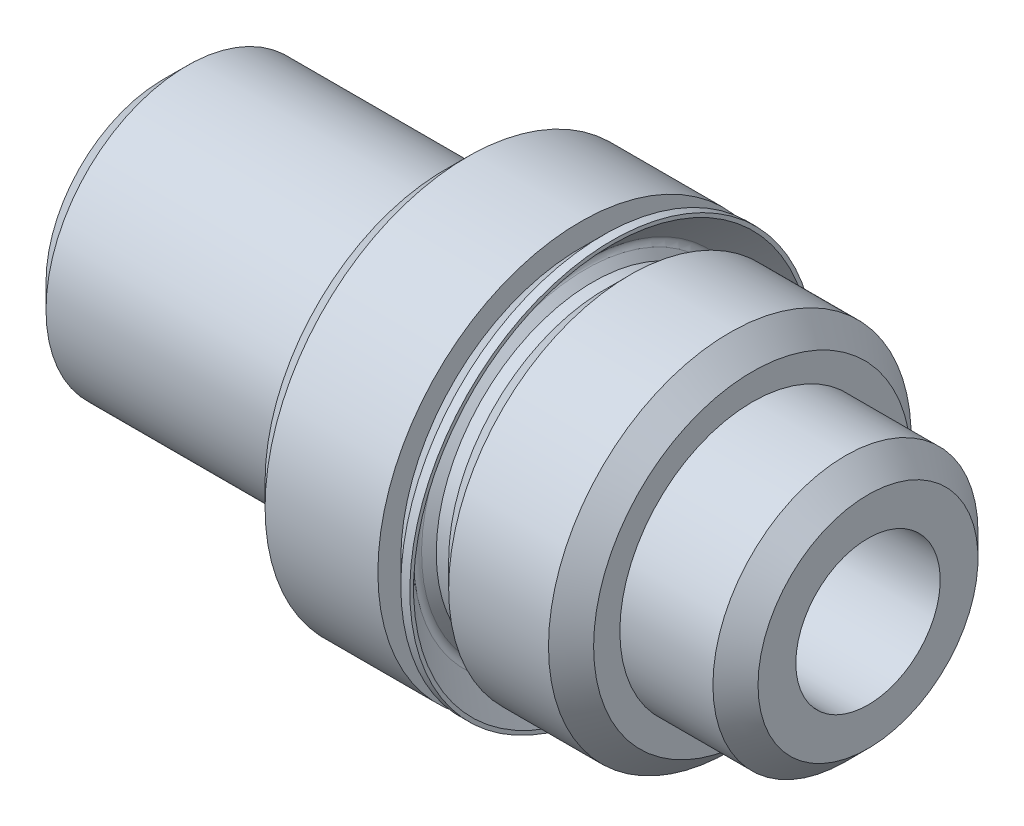
from build123d import *

# Parameters (mm, degrees)
HOLE1_D           = 3.2512
HOLE1_CSINK_D     = 4.0132
HOLE1_CSINK_ANGLE = 90


with BuildPart() as part:
    # Sketch1 → Revolve1 (revolve)
    with BuildSketch(Plane.XY):
        Polygon((0, 0), (0, 2.63398), (0.54102, 3.175), (6.35, 3.175), (6.35, 0), align=None)
    revolve(axis=Axis((6.35, 0, 0), (-1, 0, 0)))

    # Sketch2 → Revolve2 (revolve)
    with BuildSketch(Plane.XY):
        Polygon((6.35, 0), (6.35, 4.0513), (6.858, 4.5593), (9.398, 4.5593), (9.398, 3.52425), (9.9568, 3.52425), (10.5156, 4.08305), (12.7635, 4.08305), (13.2715, 3.57505), (13.2715, 0), align=None)
    revolve(axis=Axis((13.2715, 0, 0), (-1, 0, 0)))

    # Sketch3 → Revolve3 (revolve)
    with BuildSketch(Plane.XY):
        Polygon((13.2715, 0), (13.2715, 2.9845), (15.367, 2.9845), (15.875, 2.4765), (15.875, 0), align=None)
    revolve(axis=Axis((15.875, 0, 0), (-1, 0, 0)))

    # Hole1 (through all)
    with Locations(Plane.ZY):
        with Locations((0, 0)):
            CounterSinkHole(HOLE1_D / 2, HOLE1_CSINK_D / 2, counter_sink_angle=HOLE1_CSINK_ANGLE)

    # Sketch6 → Revolve4 (revolve)
    with BuildSketch(Plane.XY):
        with BuildLine():
            Line((9.398, 3.27025), (9.9568, 3.27025))
            Line((9.9568, 3.27025), (9.9568, 3.52425))
            Line((9.9568, 3.52425), (9.6774, 3.52425))
            Line((9.6774, 3.52425), (9.511771292, 3.689878708))
            ThreePointArc((9.511771292, 3.689878708), (9.474573853, 3.779681269), (9.511771292, 3.869483831))
            Line((9.511771292, 3.869483831), (10.117419265, 4.475131804))
            Line((10.117419265, 4.475131804), (10.117419265, 4.5593))
            Line((10.117419265, 4.5593), (9.914219265, 4.5593))
            Line((9.914219265, 4.5593), (9.398, 4.043080735))
            Line((9.398, 4.043080735), (9.398, 3.27025))
        make_face()
    revolve(axis=Axis((9.9568, 0, 0), (-1, 0, 0)))


solid = part.part
